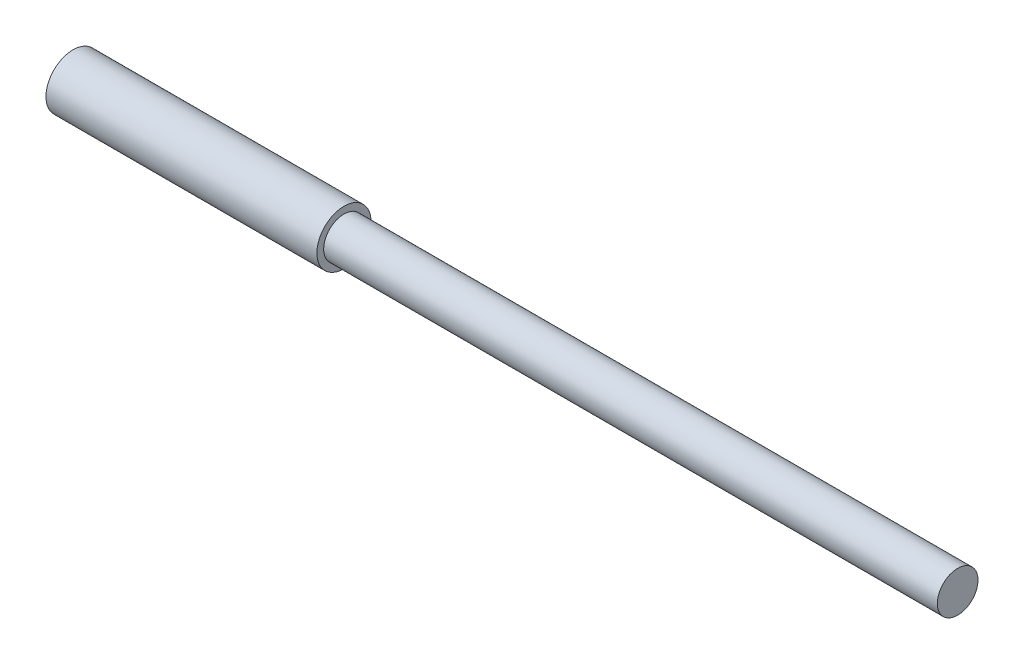
from build123d import *

# Parameters (mm, degrees)
ESQUISSE1_R      = 2
EXTRUSION1_DEPTH = 20
ESQUISSE2_R      = 1.5
EXTRUSION2_DEPTH = 45.3


with BuildPart() as part:
    # Esquisse1 → Extrusion1 (new body)
    with BuildSketch(Plane(origin=(0, 0, 0), x_dir=(0, 0, -1), z_dir=(1, 0, 0))):
        Circle(ESQUISSE1_R)
    extrude(amount=EXTRUSION1_DEPTH)

    # Esquisse2 → Extrusion2 (add)
    with BuildSketch(Plane(origin=(20, 0, 0), x_dir=(0, 0, -1), z_dir=(1, 0, 0))):
        Circle(ESQUISSE2_R)
    extrude(amount=EXTRUSION2_DEPTH)


solid = part.part
